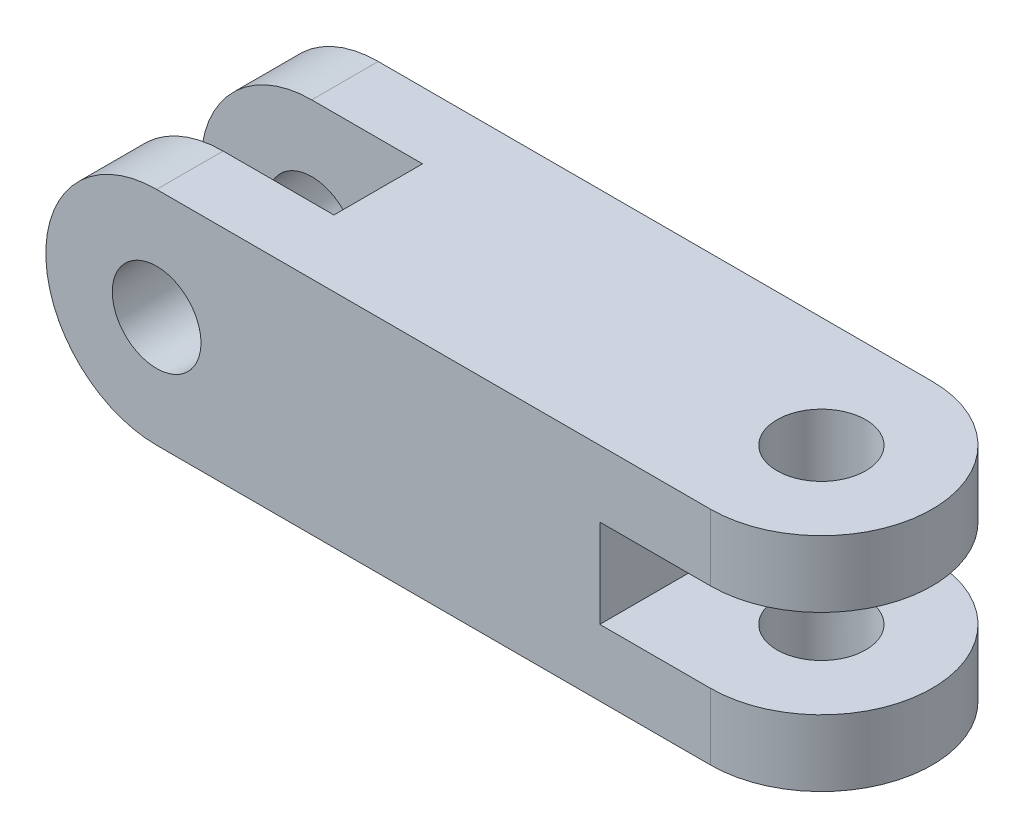
from build123d import *

# Parameters (mm, degrees)
BOSS_EXTRUDE1_DEPTH = 50
BOSS_EXTRUDE4_DEPTH = 50
SKETCH5_W           = 50
SKETCH5_H           = 20
CUT_EXTRUDE2_DEPTH  = 50
SKETCH6_W           = 50
SKETCH6_H           = 20
CUT_EXTRUDE3_DEPTH  = 50
SKETCH7_R           = 10
CUT_EXTRUDE4_DEPTH  = 50
SKETCH8_R           = 10
CUT_EXTRUDE5_DEPTH  = 50


with BuildPart() as part:
    # Sketch2 → Boss-Extrude1 (new body)
    with BuildSketch(Plane(origin=(0, 0, 0), x_dir=(1, 0, 0), z_dir=(0, 1, 0))):
        with BuildLine():
            Line((-60, 25), (65, 25))
            ThreePointArc((65, 25), (90, 0), (65, -25))
            Line((65, -25), (-60, -25))
            Line((-60, -25), (-60, 25))
        make_face()
    extrude(amount=BOSS_EXTRUDE1_DEPTH)

    # Sketch3 → Boss-Extrude4 (add)
    with BuildSketch(Plane.XY.offset(25)):
        with BuildLine():
            Line((-60, 50), (-60, 0))
            ThreePointArc((-60, 0), (-85, 25), (-60, 50))
        make_face()
    extrude(amount=-BOSS_EXTRUDE4_DEPTH)

    # Sketch5 → Cut-Extrude2 (cut)
    with BuildSketch(Plane(origin=(0, 50, 0), x_dir=(1, 0, 0), z_dir=(0, 1, 0))):
        with Locations((-60, 0)):
            Rectangle(SKETCH5_W, SKETCH5_H)
    extrude(amount=-CUT_EXTRUDE2_DEPTH, mode=Mode.SUBTRACT)

    # Sketch6 → Cut-Extrude3 (cut)
    with BuildSketch(Plane.XY.offset(25)):
        with Locations((65, 25)):
            Rectangle(SKETCH6_W, SKETCH6_H)
    extrude(amount=-CUT_EXTRUDE3_DEPTH, mode=Mode.SUBTRACT)

    # Sketch7 → Cut-Extrude4 (cut)
    with BuildSketch(Plane(origin=(0, 50, 0), x_dir=(1, 0, 0), z_dir=(0, 1, 0))):
        with Locations((65, 0)):
            Circle(SKETCH7_R)
    extrude(amount=-CUT_EXTRUDE4_DEPTH, mode=Mode.SUBTRACT)

    # Sketch8 → Cut-Extrude5 (cut)
    with BuildSketch(Plane(origin=(0, 0, -25), x_dir=(-1, 0, 0), z_dir=(0, 0, -1))):
        with Locations((60, 25)):
            Circle(SKETCH8_R)
    extrude(amount=-CUT_EXTRUDE5_DEPTH, mode=Mode.SUBTRACT)


solid = part.part
